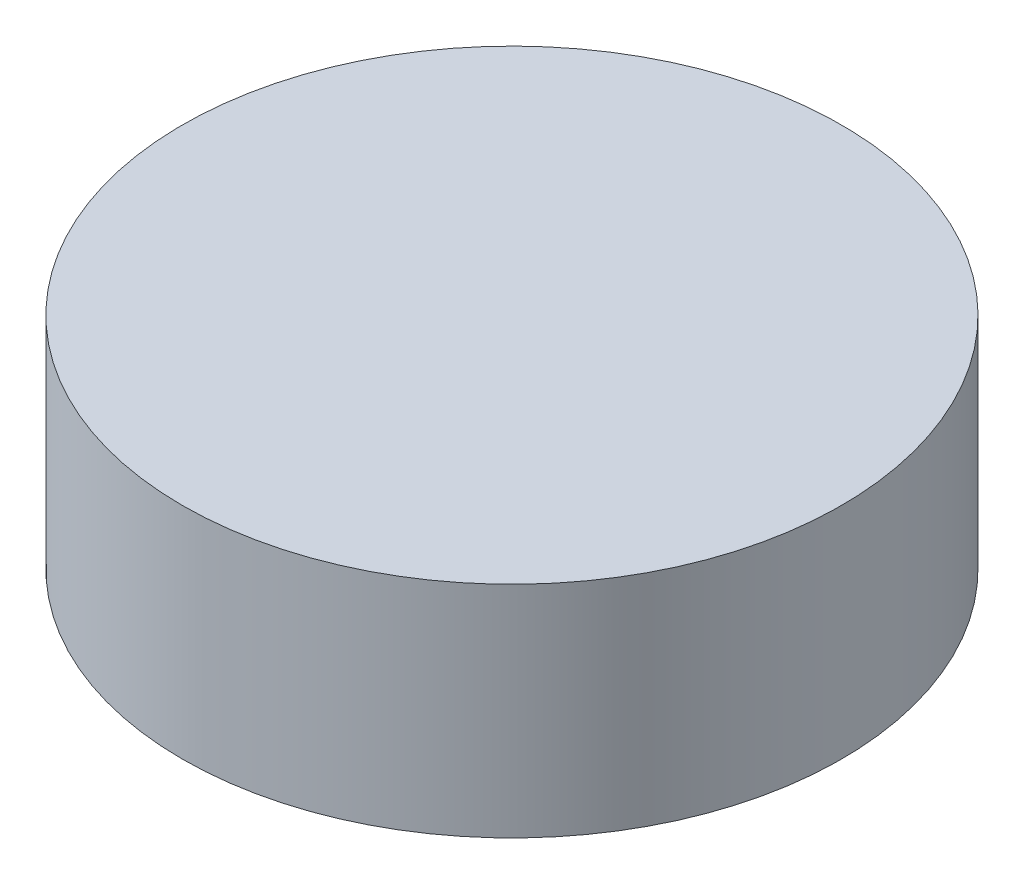
from build123d import *

# Parameters (mm, degrees)
SKETCH1_R           = 3
BOSS_EXTRUDE1_DEPTH = 2


with BuildPart() as part:
    # Sketch1 → Boss-Extrude1 (new body)
    with BuildSketch(Plane(origin=(0, 0, 0), x_dir=(1, 0, 0), z_dir=(0, 1, 0))):
        Circle(SKETCH1_R)
    extrude(amount=BOSS_EXTRUDE1_DEPTH)


solid = part.part
